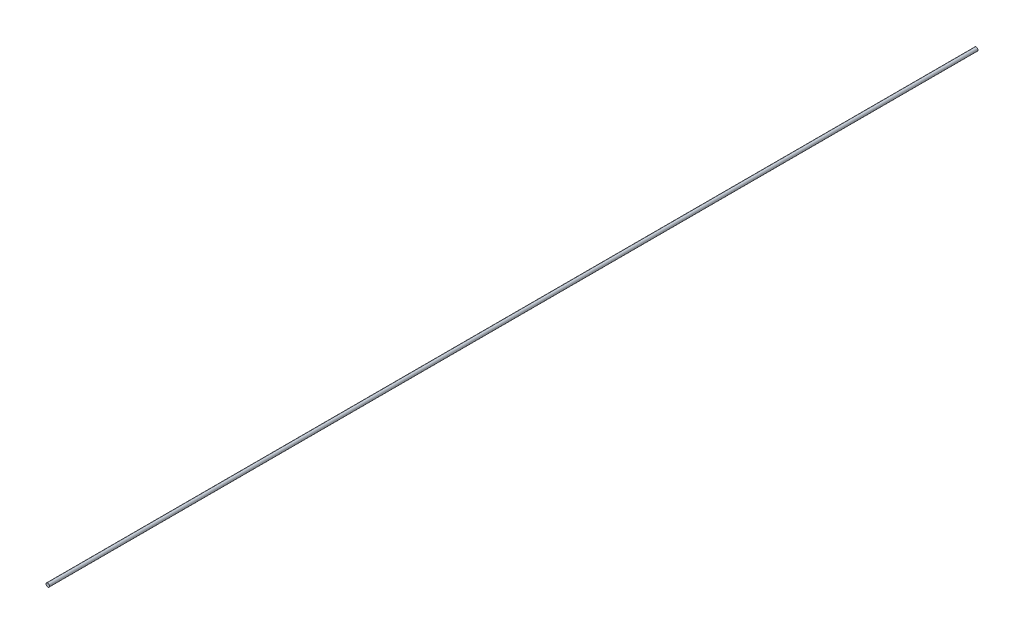
from build123d import *

# Parameters (mm, degrees)
SKETCH1_R           = 3.8
BOSS_EXTRUDE1_DEPTH = 2000


with BuildPart() as part:
    # Sketch1 → Boss-Extrude1 (new body)
    with BuildSketch(Plane.XY):
        Circle(SKETCH1_R)
    extrude(amount=BOSS_EXTRUDE1_DEPTH)


solid = part.part
